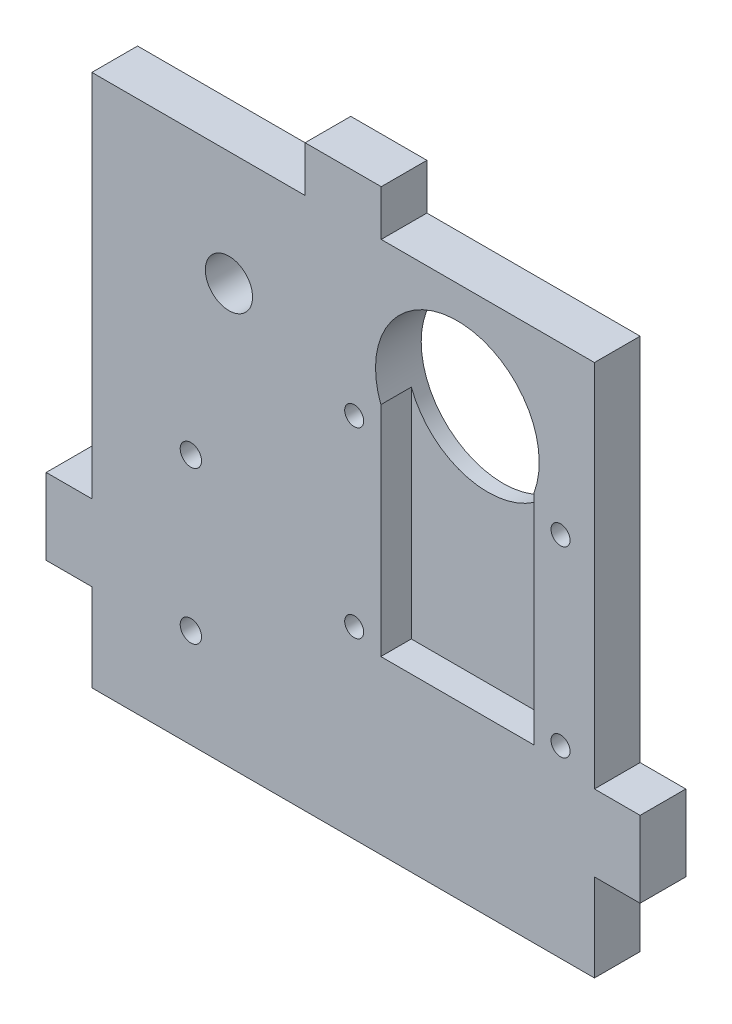
from build123d import *

# Parameters (mm, degrees)
ESQUISSE1_W             = 66
ESQUISSE1_H             = 70
ESQUISSE1_R             = 10.75
ESQUISSE1_R_2           = 1.4
ESQUISSE1_R_3           = 3.1
BOSS_EXTRU_1_DEPTH      = 6
ESQUISSE2_W             = 10
ESQUISSE2_H             = 6
ESQUISSE2_W_2           = 6
ESQUISSE2_H_2           = 10
BOSS_EXTRU_3_DEPTH      = 6
ENL_V_MAT_EXTRU_3_DEPTH = 4
ESQUISSE4_R             = 1.25
ENL_V_MAT_EXTRU_4_DEPTH = 6


with BuildPart() as part:
    # Esquisse1 → Boss.-Extru.1 (new body)
    with BuildSketch(Plane.XY):
        with Locations((0, -20)):
            Rectangle(ESQUISSE1_W, ESQUISSE1_H)
        with Locations((15, 0)):
            Circle(ESQUISSE1_R, mode=Mode.SUBTRACT)
        with Locations((-20, -42)):
            Circle(ESQUISSE1_R_2, mode=Mode.SUBTRACT)
        with Locations((-20, -22)):
            Circle(ESQUISSE1_R_2, mode=Mode.SUBTRACT)
        with Locations((-15, 0)):
            Circle(ESQUISSE1_R_3, mode=Mode.SUBTRACT)
    extrude(amount=BOSS_EXTRU_1_DEPTH)

    # Esquisse2 → Boss.-Extru.3 (add)
    with BuildSketch(Plane.XY.offset(6)):
        with Locations((0, 18)):
            Rectangle(ESQUISSE2_W, ESQUISSE2_H)
        with Locations((-36, -38.5)):
            Rectangle(ESQUISSE2_W_2, ESQUISSE2_H_2)
        with Locations((36, -38.5)):
            Rectangle(ESQUISSE2_W_2, ESQUISSE2_H_2)
    extrude(amount=-BOSS_EXTRU_3_DEPTH)

    # Esquisse3 → Enlèv. mat.-Extru.3 (cut)
    with BuildSketch(Plane.XY.offset(6)):
        with BuildLine():
            Line((4.95, -3.815756806), (4.95, -32.465756806))
            Line((4.95, -32.465756806), (25.05, -32.465756806))
            Line((25.05, -32.465756806), (25.05, -3.815756806))
            ThreePointArc((25.05, -3.815756806), (15, -10.75), (4.95, -3.815756806))
        make_face()
    extrude(amount=-ENL_V_MAT_EXTRU_3_DEPTH, mode=Mode.SUBTRACT)

    # Esquisse4 → Enlèv. mat.-Extru.4 (cut)
    with BuildSketch(Plane.XY.offset(6)):
        with Locations((28.55, -6.815756806)):
            Circle(ESQUISSE4_R)
        with Locations((28.55, -30.815756806)):
            Circle(ESQUISSE4_R)
        with Locations((1.45, -30.815756806)):
            Circle(ESQUISSE4_R)
        with Locations((1.45, -6.815756806)):
            Circle(ESQUISSE4_R)
    extrude(amount=-ENL_V_MAT_EXTRU_4_DEPTH, mode=Mode.SUBTRACT)


solid = part.part
